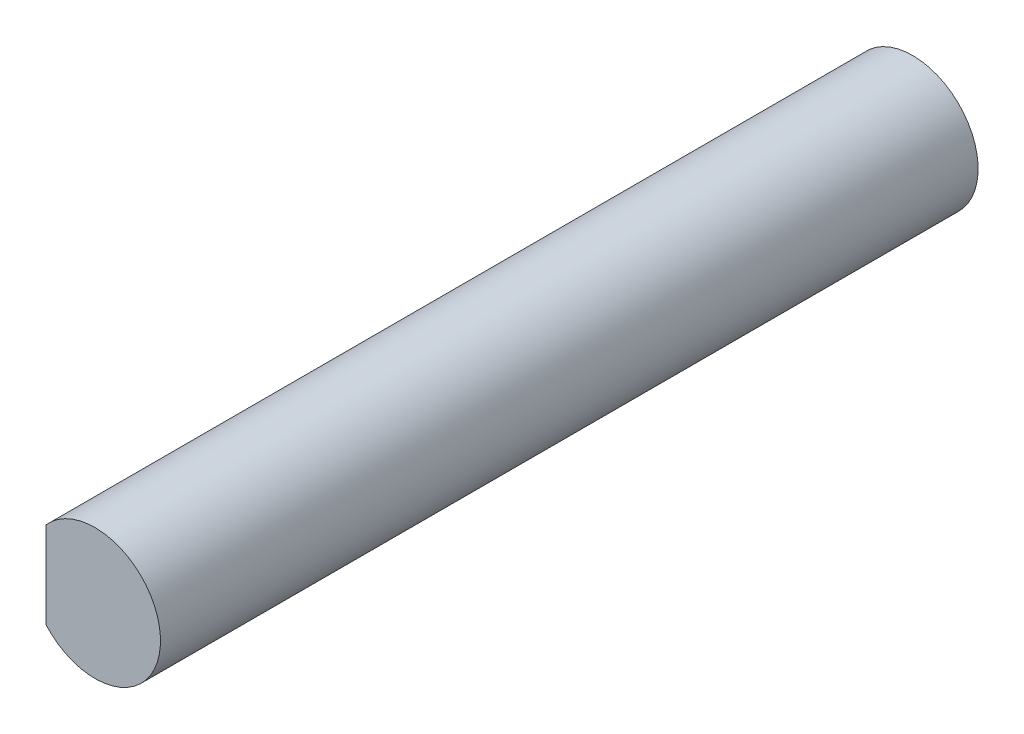
from build123d import *

# Parameters (mm, degrees)
BOSS_EXTRUDE1_DEPTH = 25


with BuildPart() as part:
    # Sketch1 → Boss-Extrude1 (new body)
    with BuildSketch(Plane.XY):
        with BuildLine():
            Line((-1.5, 1.322875656), (-1.5, -1.322875656))
            ThreePointArc((-1.5, -1.322875656), (2, 0), (-1.5, 1.322875656))
        make_face()
    extrude(amount=BOSS_EXTRUDE1_DEPTH)


solid = part.part
